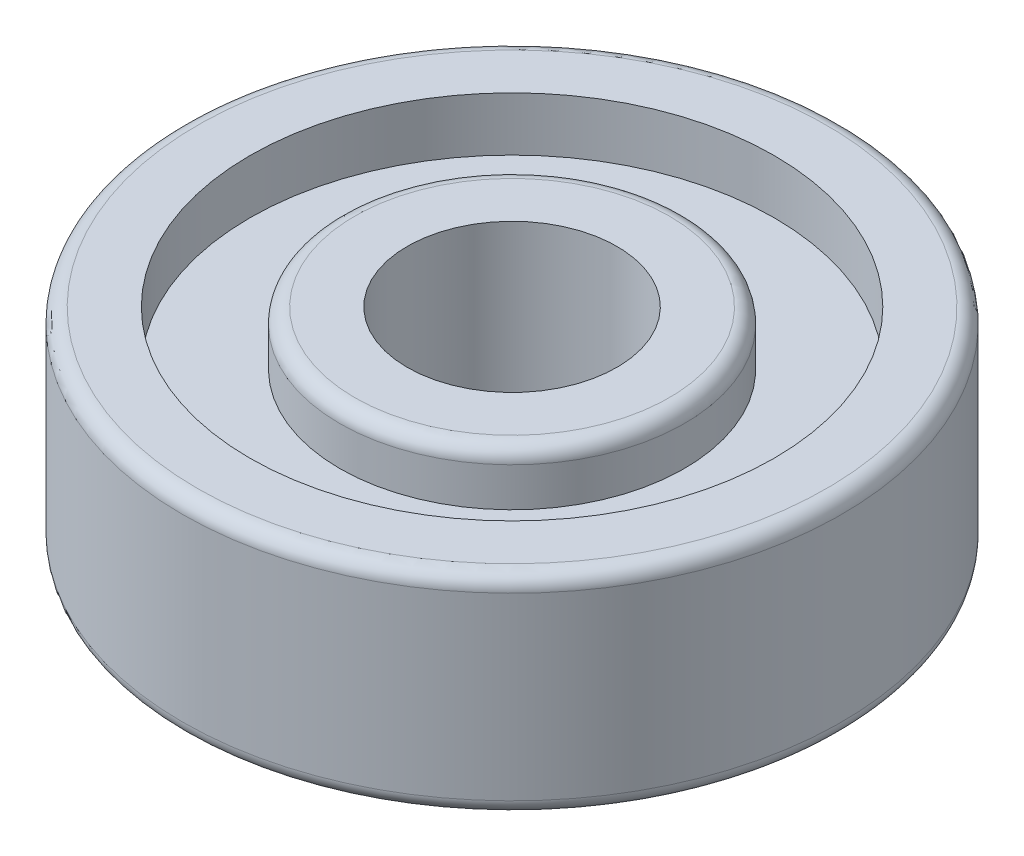
from build123d import *

# Parameters (mm, degrees)
SKETCH1_R           = 11
BOSS_EXTRUDE1_DEPTH = 3.5
SKETCH3_R           = 3.5
CUT_EXTRUDE1_DEPTH  = 18.058722109
SKETCH3_3_R         = 8.75
SKETCH3_3_R_2       = 5.75
CUT_EXTRUDE2_DEPTH  = 1.8
FILLET1_R           = 0.5


with BuildPart() as part:
    # Sketch1 → Boss-Extrude1 (new, symmetric)
    with BuildSketch(Plane(origin=(0, 0, 0), x_dir=(1, 0, 0), z_dir=(0, 1, 0))):
        Circle(SKETCH1_R)
    extrude(amount=BOSS_EXTRUDE1_DEPTH, both=True)

    # Sketch3 → Cut-Extrude1 (cut, through all)
    with BuildSketch(Plane(origin=(0, 3.5, 0), x_dir=(1, 0, 0), z_dir=(0, 1, 0))):
        Circle(SKETCH3_R)
    extrude(amount=-CUT_EXTRUDE1_DEPTH, mode=Mode.SUBTRACT)

    # Sketch3_3 → Cut-Extrude2 (cut)
    with BuildSketch(Plane(origin=(0, 3.5, 0), x_dir=(1, 0, 0), z_dir=(0, 1, 0))):
        Circle(SKETCH3_3_R)
        Circle(SKETCH3_3_R_2, mode=Mode.SUBTRACT)
    cut_extrude2 = extrude(amount=-CUT_EXTRUDE2_DEPTH, mode=Mode.SUBTRACT)

    # Mirror1: Cut-Extrude2 across plane
    add(cut_extrude2.mirror(Plane.ZX), mode=Mode.SUBTRACT)

    # Fillet1
    fillet1_edges = [part.edges().sort_by_distance(p)[0] for p in [
        (-5.75, 3.5, 0),
        (-11, 3.5, 0),
        (-5.75, -3.5, 0),
        (-11, -3.5, 0),
    ]]
    fillet(fillet1_edges, radius=FILLET1_R)


solid = part.part
